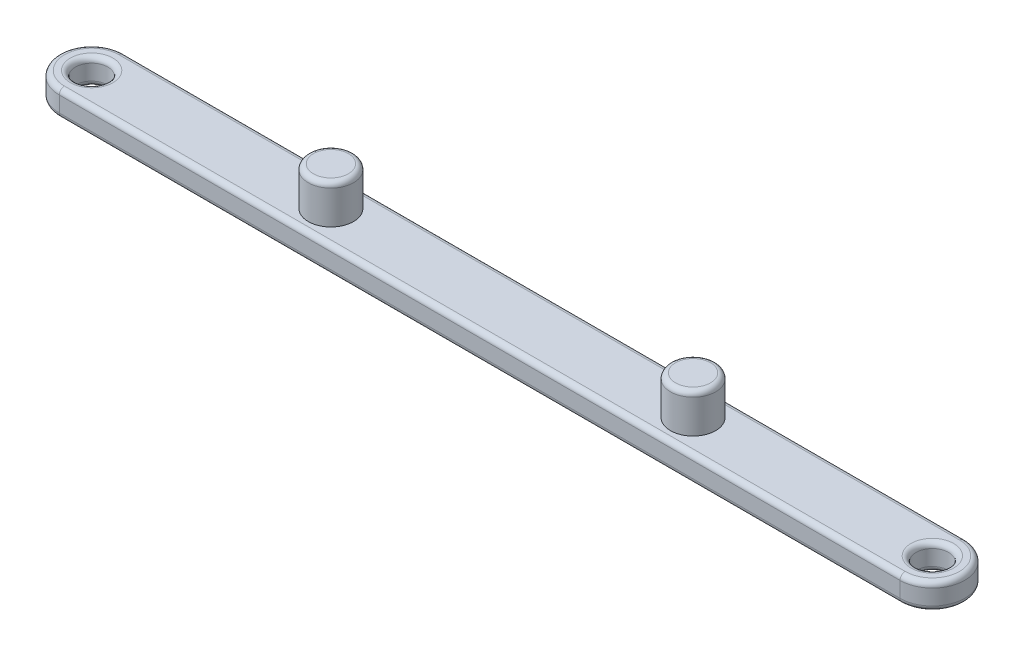
from build123d import *

# Parameters (mm, degrees)
SKETCH_1_R      = 1.25
EXTRUDE_1_DEPTH = 2
SKETCH_2_R      = 1.75
EXTRUDE_2_DEPTH = 3
FILLET_1_R      = 0.4


with BuildPart() as part:
    # 草图1 → 凸台-拉伸1 (new body)
    with BuildSketch(Plane(origin=(0, 0, 0), x_dir=(1, 0, 0), z_dir=(0, 1, 0))):
        with BuildLine():
            Line((-32.5, 2.5), (32.5, 2.5))
            ThreePointArc((32.5, 2.5), (35, 0), (32.5, -2.5))
            Line((32.5, -2.5), (-32.5, -2.5))
            ThreePointArc((-32.5, -2.5), (-35, 0), (-32.5, 2.5))
        make_face()
        with Locations((-32.5, 0)):
            Circle(SKETCH_1_R, mode=Mode.SUBTRACT)
        with Locations((32.5, 0)):
            Circle(SKETCH_1_R, mode=Mode.SUBTRACT)
    extrude(amount=EXTRUDE_1_DEPTH)

    # 草图2 → 凸台-拉伸2 (add)
    with BuildSketch(Plane(origin=(0, 2, 0), x_dir=(1, 0, 0), z_dir=(0, 1, 0))):
        with Locations((14, 0)):
            Circle(SKETCH_2_R)
        with Locations((-14, 0)):
            Circle(SKETCH_2_R)
    extrude(amount=EXTRUDE_2_DEPTH)

    # 圆角1
    fillet_1_edges = [part.edges().sort_by_distance(p)[0] for p in [
        (-33.75, 0, 0),
        (-33.75, 2, 0),
        (35, 2, 0),
        (31.25, 0, 0),
        (31.25, 2, 0),
        (0, 2, -2.5),
        (12.25, 5, 0),
        (-15.75, 5, 0),
        (-35, 2, 0),
        (0, 0, -2.5),
        (35, 0, 0),
        (0, 0, 2.5),
        (-35, 0, 0),
        (0, 2, 2.5),
    ]]
    fillet(fillet_1_edges, radius=FILLET_1_R)


solid = part.part
